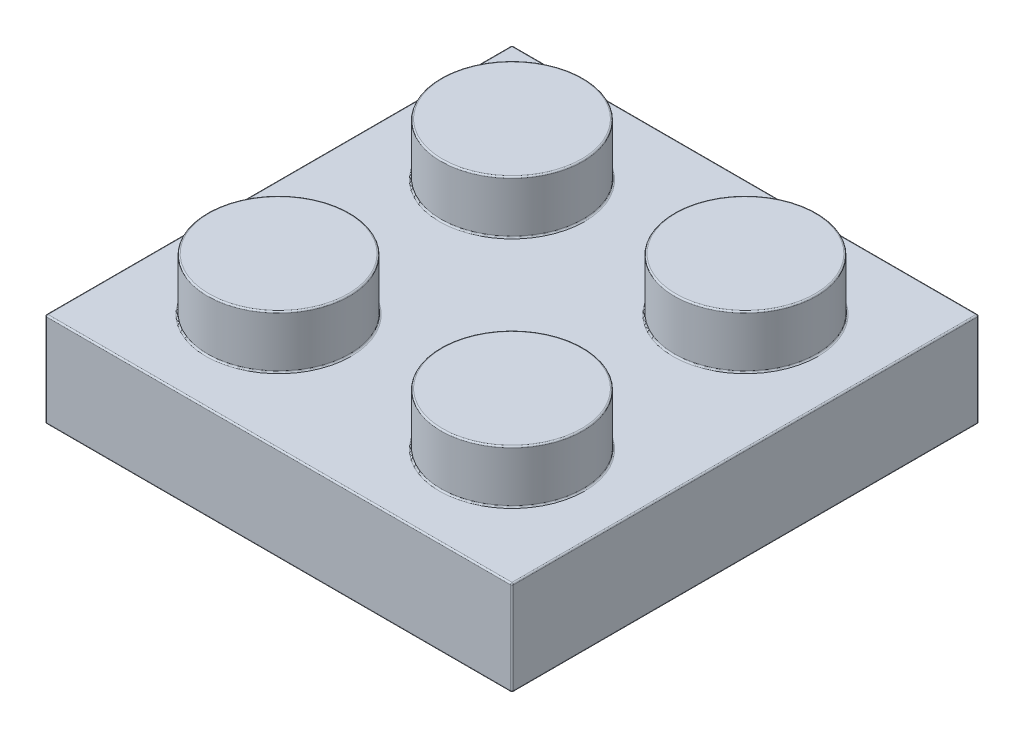
from build123d import *

# Parameters (mm, degrees)
SKETCH1_W                 = 7.96
SKETCH1_H                 = 7.96
EXTRUDE1_DEPTH            = 3.22
SKETCH2_R                 = 2.425
EXTRUDE2_DEPTH            = 1.8
LPATTERN1_COUNT           = 2
LPATTERN1_PITCH           = 7.96
LPATTERN2_COUNT           = 2
LPATTERN2_PITCH           = 7.96
LPATTERN2_COPY_1_SKETCH_W = 7.96
LPATTERN2_COPY_1_SKETCH_H = 7.96
LPATTERN2_COPY_1_DEPTH    = 3.22
LPATTERN2_COPY_2_SKETCH_R = 2.425
LPATTERN2_COPY_2_DEPTH    = 1.8
SHELL1_T                  = -1.55
SKETCH3_W                 = 12.82
SKETCH3_H                 = 12.82
EXTRUDE3_DEPTH            = 0.14
SKETCH4_R                 = 3.23
SKETCH4_R_2               = 2.37
EXTRUDE4_DEPTH            = 1.81
FILLET1_R                 = 0.05


with BuildPart() as part:
    # Sketch1 → Extrude1 (new body)
    with BuildSketch(Plane(origin=(0, 0, 0), x_dir=(1, 0, 0), z_dir=(0, 1, 0))):
        Rectangle(SKETCH1_W, SKETCH1_H)
    extrude1 = extrude(amount=EXTRUDE1_DEPTH)

    # Sketch2 → Extrude2 (add)
    with BuildSketch(Plane(origin=(0, 3.22, 0), x_dir=(1, 0, 0), z_dir=(0, 1, 0))):
        Circle(SKETCH2_R)
    extrude2 = extrude(amount=EXTRUDE2_DEPTH)

    # LPattern1: Extrude1, Extrude2 ×2
    with Locations(*[(i * LPATTERN1_PITCH, 0, 0) for i in range(1, LPATTERN1_COUNT)]):
        add(extrude1)
        add(extrude2)

    # LPattern2: Extrude1, Extrude2 ×2
    with Locations(*[(0, 0, -i * LPATTERN2_PITCH) for i in range(1, LPATTERN2_COUNT)]):
        add(extrude1)
        add(extrude2)

    # LPattern2 copy 1 sketch → LPattern2 copy 1 (add)
    with BuildSketch(Plane(origin=(7.96, 0, -7.96), x_dir=(1, 0, 0), z_dir=(0, 1, 0))):
        Rectangle(LPATTERN2_COPY_1_SKETCH_W, LPATTERN2_COPY_1_SKETCH_H)
    extrude(amount=LPATTERN2_COPY_1_DEPTH)

    # LPattern2 copy 2 sketch → LPattern2 copy 2 (add)
    with BuildSketch(Plane(origin=(7.96, 3.22, -7.96), x_dir=(1, 0, 0), z_dir=(0, 1, 0))):
        Circle(LPATTERN2_COPY_2_SKETCH_R)
    extrude(amount=LPATTERN2_COPY_2_DEPTH)

    # Shell1
    shell1_openings = [part.faces().sort_by_distance(p)[0] for p in [
        (3.98, 0, -3.98),
    ]]
    offset(amount=SHELL1_T, openings=shell1_openings, kind=Kind.INTERSECTION)

    # Sketch3 → Extrude3 (cut)
    with BuildSketch(Plane.XZ.offset(-1.67)):
        with Locations((3.98, -3.98)):
            Rectangle(SKETCH3_W, SKETCH3_H)
    extrude(amount=-EXTRUDE3_DEPTH, mode=Mode.SUBTRACT)

    # Sketch4 → Extrude4 (add)
    with BuildSketch(Plane.XZ.offset(-1.81)):
        with Locations((3.98, -3.98)):
            Circle(SKETCH4_R)
        with Locations((3.98, -3.98)):
            Circle(SKETCH4_R_2, mode=Mode.SUBTRACT)
    extrude(amount=EXTRUDE4_DEPTH)

    # Fillet1
    fillet1_edges = [part.edges().sort_by_distance(p)[0] for p in [
        (-3.98, 3.22, -3.98),
        (3.98, 3.22, 3.98),
        (-2.425, 3.22, 0),
        (-2.425, 5.02, 0),
        (11.94, 0, -3.98),
        (11.94, 1.61, 3.98),
        (11.94, 3.22, -3.98),
        (5.535, 3.22, 0),
        (5.535, 5.02, 0),
        (3.98, 0, -11.94),
        (11.94, 1.61, -11.94),
        (-3.98, 1.61, -11.94),
        (3.98, 3.22, -11.94),
        (3.98, 0, 3.98),
        (-2.425, 3.22, -7.96),
        (-2.425, 5.02, -7.96),
        (5.535, 3.22, -7.96),
        (5.535, 5.02, -7.96),
        (-3.98, 0, -3.98),
        (-2.43, 0, -3.98),
        (-2.43, 0.905, -10.39),
        (3.98, 0, 2.43),
        (-2.43, 0.905, 2.43),
        (-0.875, 3.47, 0),
        (10.39, 0, -3.98),
        (10.39, 0.905, 2.43),
        (7.085, 3.47, 0),
        (3.98, 0, -10.39),
        (10.39, 0.905, -10.39),
        (-0.875, 3.47, -7.96),
        (7.085, 3.47, -7.96),
        (-0.875, 1.81, 0),
        (7.085, 1.81, 0),
        (-0.875, 1.81, -7.96),
        (7.085, 1.81, -7.96),
        (10.39, 1.81, -3.98),
        (3.98, 1.81, -10.39),
        (-3.98, 1.61, 3.98),
        (-2.43, 1.81, -3.98),
        (3.98, 1.81, 2.43),
        (0.75, 1.81, -3.98),
        (1.61, 1.81, -3.98),
        (0.75, 0, -3.98),
        (1.61, 0, -3.98),
    ]]
    fillet(fillet1_edges, radius=FILLET1_R)


solid = part.part
